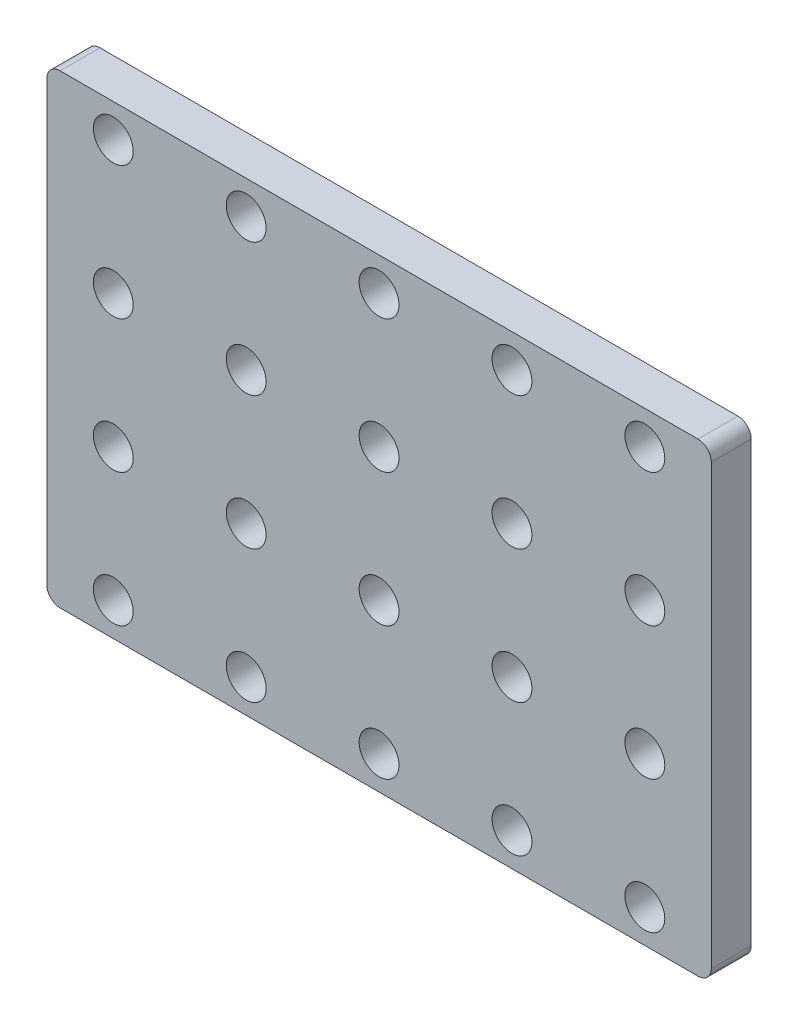
from build123d import *

# Parameters (mm, degrees)
ESQUISSE1_W             = 50
ESQUISSE1_H             = 35
BOSS_EXTRU_1_DEPTH      = 3
ESQUISSE2_R             = 1.5
ENL_V_MAT_EXTRU_1_DEPTH = 3
CONG_1_R                = 1


with BuildPart() as part:
    # Esquisse1 → Boss.-Extru.1 (new body)
    with BuildSketch(Plane.XY):
        with Locations((25, 17.5)):
            Rectangle(ESQUISSE1_W, ESQUISSE1_H)
    extrude(amount=BOSS_EXTRU_1_DEPTH)

    # Esquisse2 → Enlèv. mat.-Extru.1 (cut)
    with BuildSketch(Plane.XY.offset(3)):
        with Locations((5, 32.5)):
            Circle(ESQUISSE2_R)
        with Locations((15, 32.5)):
            Circle(ESQUISSE2_R)
        with Locations((25, 32.5)):
            Circle(ESQUISSE2_R)
        with Locations((35, 32.5)):
            Circle(ESQUISSE2_R)
        with Locations((45, 32.5)):
            Circle(ESQUISSE2_R)
        with Locations((15, 22.5)):
            Circle(ESQUISSE2_R)
        with Locations((25, 22.5)):
            Circle(ESQUISSE2_R)
        with Locations((35, 22.5)):
            Circle(ESQUISSE2_R)
        with Locations((45, 22.5)):
            Circle(ESQUISSE2_R)
        with Locations((15, 12.5)):
            Circle(ESQUISSE2_R)
        with Locations((25, 12.5)):
            Circle(ESQUISSE2_R)
        with Locations((35, 12.5)):
            Circle(ESQUISSE2_R)
        with Locations((45, 12.5)):
            Circle(ESQUISSE2_R)
        with Locations((15, 2.5)):
            Circle(ESQUISSE2_R)
        with Locations((25, 2.5)):
            Circle(ESQUISSE2_R)
        with Locations((35, 2.5)):
            Circle(ESQUISSE2_R)
        with Locations((45, 2.5)):
            Circle(ESQUISSE2_R)
        with Locations((5, 22.5)):
            Circle(ESQUISSE2_R)
        with Locations((5, 12.5)):
            Circle(ESQUISSE2_R)
        with Locations((5, 2.5)):
            Circle(ESQUISSE2_R)
    extrude(amount=-ENL_V_MAT_EXTRU_1_DEPTH, mode=Mode.SUBTRACT)

    # Congé1
    cong_1_edges = [part.edges().sort_by_distance(p)[0] for p in [
        (0, 35, 1.5),
        (50, 35, 1.5),
        (50, 0, 1.5),
        (0, 0, 1.5),
    ]]
    fillet(cong_1_edges, radius=CONG_1_R)


solid = part.part
